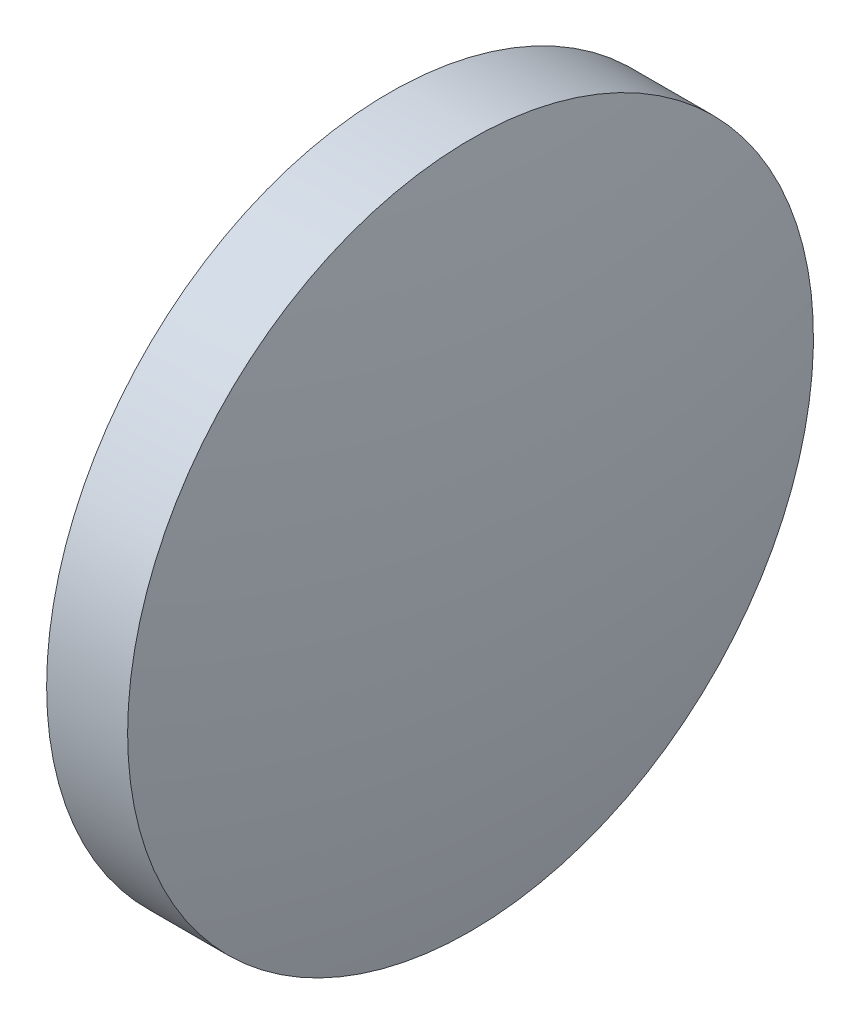
from build123d import *


with BuildPart() as part:
    # 草图1 → 旋转1 (revolve)
    with BuildSketch(Plane.XY, mode=Mode.PRIVATE) as revolve_1_sk:
        with BuildLine():
            Line((115.773606431, 65.233554926), (115.773606431, 77.933554926))
            Line((115.773606431, 77.933554926), (118.773155255, 77.933554926))
            ThreePointArc((118.773155255, 77.933554926), (119.658607359, 71.610972642), (119.954606431, 65.233554926))
            Line((119.954606431, 65.233554926), (115.773606431, 65.233554926))
        make_face()
    revolve(revolve_1_sk.sketch.rotate(Axis((110.165373228, 65.233554926, 0), (1, 0, 0)), 180), axis=Axis((110.165373228, 65.233554926, 0), (1, 0, 0)))  # turned: the seam where the file's is


solid = part.part
